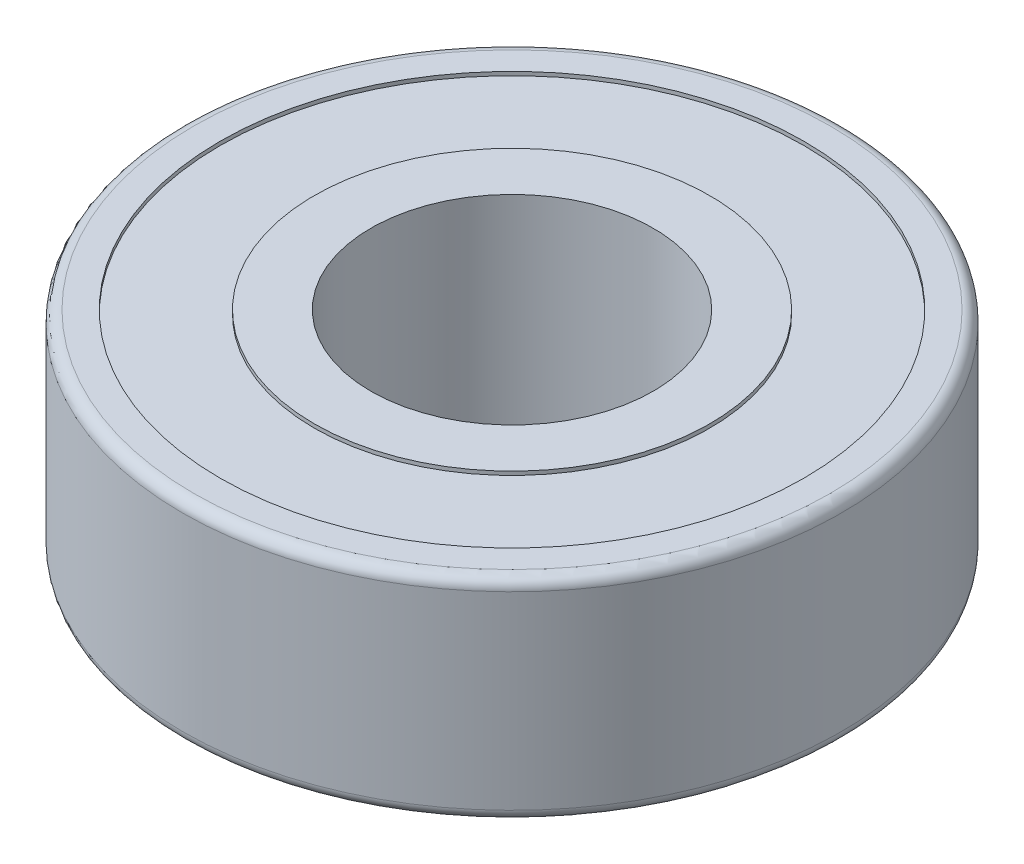
from build123d import *

# Parameters (mm, degrees)
SKETCH1_R           = 11.1125
SKETCH1_R_2         = 4.7625
BOSS_EXTRUDE1_DEPTH = 7.14375
SKETCH2_R           = 9.8425
SKETCH2_R_2         = 6.6675
CUT_EXTRUDE1_DEPTH  = 0.127
SKETCH3_R           = 9.8425
SKETCH3_R_2         = 6.6675
CUT_EXTRUDE3_DEPTH  = 0.127
FILLET1_R           = 0.381


with BuildPart() as part:
    # Sketch1 → Boss-Extrude1 (new body)
    with BuildSketch(Plane(origin=(0, 0, 0), x_dir=(1, 0, 0), z_dir=(0, 1, 0))):
        Circle(SKETCH1_R)
        Circle(SKETCH1_R_2, mode=Mode.SUBTRACT)
    extrude(amount=BOSS_EXTRUDE1_DEPTH)

    # Sketch2 → Cut-Extrude1 (cut)
    with BuildSketch(Plane(origin=(0, 7.14375, 0), x_dir=(1, 0, 0), z_dir=(0, 1, 0))):
        Circle(SKETCH2_R)
        Circle(SKETCH2_R_2, mode=Mode.SUBTRACT)
    extrude(amount=-CUT_EXTRUDE1_DEPTH, mode=Mode.SUBTRACT)

    # Sketch3 → Cut-Extrude3 (cut)
    with BuildSketch(Plane.XZ):
        Circle(SKETCH3_R)
        Circle(SKETCH3_R_2, mode=Mode.SUBTRACT)
    extrude(amount=-CUT_EXTRUDE3_DEPTH, mode=Mode.SUBTRACT)

    # Fillet1
    fillet1_edges = [part.edges().sort_by_distance(p)[0] for p in [
        (-11.1125, 0, 0),
        (-11.1125, 7.14375, 0),
    ]]
    fillet(fillet1_edges, radius=FILLET1_R)


solid = part.part
